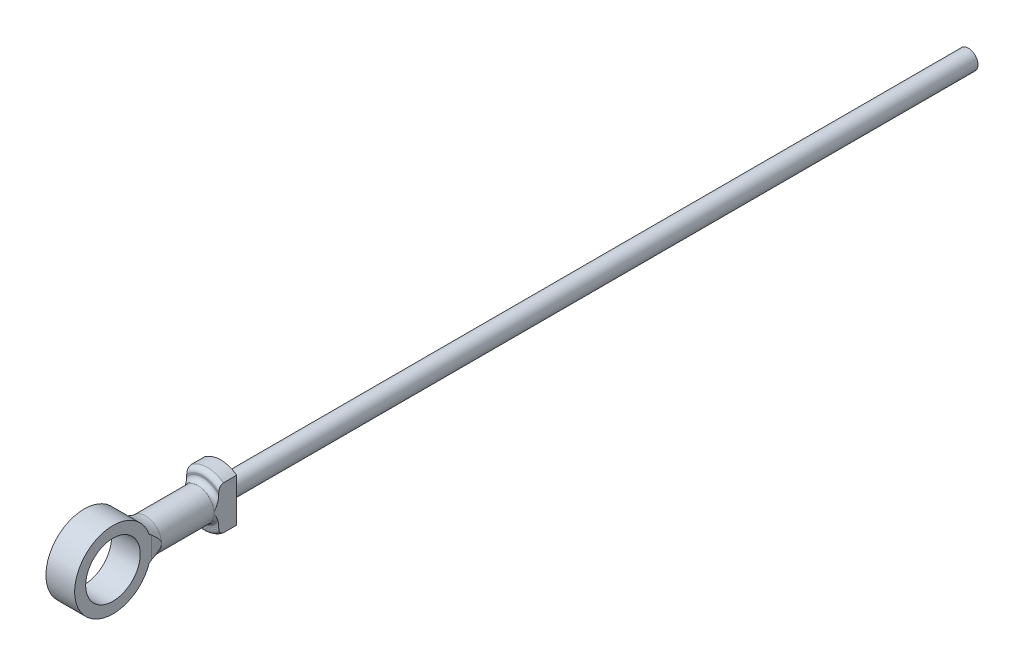
from build123d import *

# Parameters (mm, degrees)
SKETCH1_R                = 2
BOSS_EXTRUDE1_DEPTH      = 156.17
SKETCH2_R                = 5.62
BOSS_EXTRUDE2_DEPTH      = 3.75
SKETCH3_R                = 3.342777959
BOSS_EXTRUDE3_DEPTH      = 14.75
FILLET4_R                = 1
FILLET5_R                = 1
BOSS_EXTRUDE4_DEPTH      = 5
BOSS_EXTRUDE4_DEPTH_BACK = 5
SKETCH4_R                = 5.7
CUT_EXTRUDE2_DEPTH       = 190.921808488
CUT_EXTRUDE2_DEPTH_BACK  = 190.921808488
SKETCH7_W                = 5.315591211
SKETCH7_H                = 6.235782502


with BuildPart() as part:
    # Sketch1 → Boss-Extrude1 (new body)
    with BuildSketch(Plane.XY):
        Circle(SKETCH1_R)
    extrude(amount=BOSS_EXTRUDE1_DEPTH)


with BuildPart() as body_2:
    # Sketch2 → Boss-Extrude2 (new body)
    with BuildSketch(Plane.XY.offset(156.17)):
        Circle(SKETCH2_R)
    extrude(amount=BOSS_EXTRUDE2_DEPTH)

    # Sketch3 → Boss-Extrude3 (add)
    with BuildSketch(Plane.XY.offset(159.92)):
        Circle(SKETCH3_R)
    extrude(amount=BOSS_EXTRUDE3_DEPTH)

    # Fillet4
    fillet4_edges = [body_2.edges().sort_by_distance(p)[0] for p in [
        (-3.342777959, 0, 159.92),
    ]]
    fillet(fillet4_edges, radius=FILLET4_R)

    # Fillet5
    fillet5_edges = [body_2.edges().sort_by_distance(p)[0] for p in [
        (-5.62, 0, 159.92),
    ]]
    fillet(fillet5_edges, radius=FILLET5_R)

    # Sketch4 → Boss-Extrude4 (add, two sides: drawn at the far end of the back side and taken through both)
    with BuildSketch(Plane(origin=(0, 0, 0), x_dir=(0, 0, -1), z_dir=(1, 0, 0)).offset(-BOSS_EXTRUDE4_DEPTH_BACK)):
        with BuildLine():
            ThreePointArc((-173.67, 0), (-174.027795759, 2.365737588), (-175.069178584, 4.519862457))
            ThreePointArc((-175.069178584, 4.519862457), (-189.67, 0), (-175.069178584, -4.519862457))
            ThreePointArc((-175.069178584, -4.519862457), (-174.027795759, -2.365737588), (-173.67, 0))
        make_face()
        with Locations((-181.67, 0)):
            Circle(SKETCH4_R, mode=Mode.SUBTRACT)
    extrude(amount=BOSS_EXTRUDE4_DEPTH + BOSS_EXTRUDE4_DEPTH_BACK)


with BuildPart() as body_3:
    # Sketch4_4 → Revolve2 (revolve)
    with BuildSketch(Plane(origin=(0, 0, 0), x_dir=(0, 0, -1), z_dir=(1, 0, 0))):
        with BuildLine():
            Line((-171.86665682, 0), (-173.67, 0))
            ThreePointArc((-173.67, 0), (-174.027795759, -2.365737588), (-175.069178584, -4.519862457))
            add(Edge.make_bspline(
                [(-175.069178584, -4.519862457), (-173.629685325, -3.535053024), (-171.86665682, -3.342777959)],
                knots=[0, 0, 0, 1, 1, 1], degree=2))
            Line((-171.86665682, -3.342777959), (-171.86665682, 0))
        make_face()
    revolve(axis=Axis((0, 0, 189.67), (0, 0, -1)))


with BuildPart() as cut_extrude2_tool:
    # Sketch7 → Cut-Extrude2 (new, two sides: drawn at the far end of the back side and taken through both)
    with BuildSketch(Plane(origin=(0, 0, 0), x_dir=(1, 0, 0), z_dir=(0, 1, 0)).offset(-CUT_EXTRUDE2_DEPTH_BACK)):
        Polygon((3, -173.67), (3.34277796, -171.86665682), (8.65836917, -171.86665682), (8.65836917, -190.916502477), (3, -190.916502477), align=None)
        Polygon((-3, -190.916502477), (-8.65836917, -190.916502477), (-8.65836917, -171.86665682), (-3.34277796, -171.86665682), (-3, -173.67), align=None)
        with Locations((-6.000573564, -157.802108749)):
            Rectangle(SKETCH7_W, SKETCH7_H)
        with Locations((6.000573564, -157.802108749)):
            Rectangle(SKETCH7_W, SKETCH7_H)
    extrude(amount=CUT_EXTRUDE2_DEPTH + CUT_EXTRUDE2_DEPTH_BACK)


with BuildPart() as body_2_1:
    add(body_2.part)

    # Cut-Extrude2: cut by cut_extrude2_tool
    add(cut_extrude2_tool.part, mode=Mode.SUBTRACT)


with BuildPart() as body_3_1:
    add(body_3.part)

    # Cut-Extrude2: cut by cut_extrude2_tool
    add(cut_extrude2_tool.part, mode=Mode.SUBTRACT)


with BuildPart() as body_2_2:
    add(body_2_1.part)

    # Combine1: union body 3
    add(body_3_1.part)


solid = Compound([part.part, body_2_2.part])
